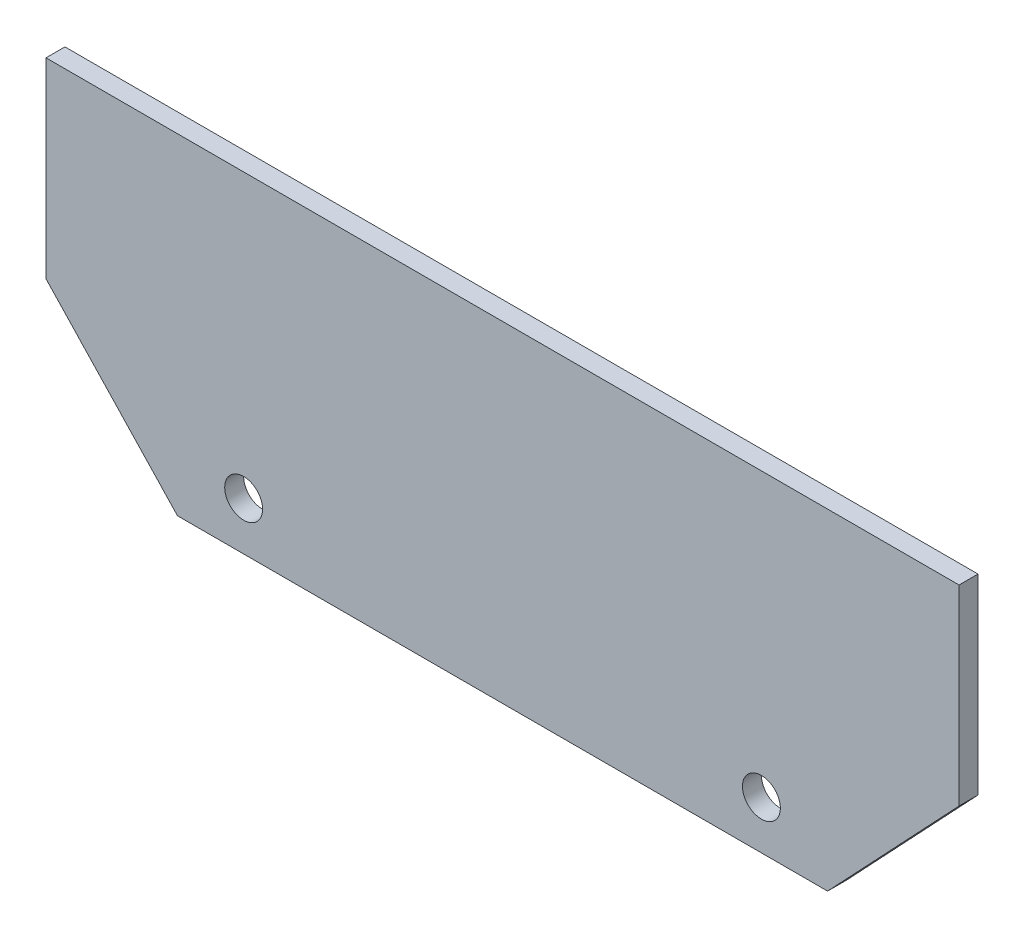
from build123d import *

# Parameters (mm, degrees)
BOSS_EXTRUDE1_DEPTH = 1.5
SKETCH3_R           = 1.5
CUT_EXTRUDE1_DEPTH  = 2.5


with BuildPart() as part:
    # Sketch2 → Boss-Extrude1 (new body)
    with BuildSketch(Plane.XY):
        Polygon((10.41, 0), (61.89, 0), (72.3, 11.044064583), (72.3, 26.2), (0, 26.2), (0, 11.044064583), align=None)
    extrude(amount=BOSS_EXTRUDE1_DEPTH)

    # Sketch3 → Cut-Extrude1 (cut, through all)
    with BuildSketch(Plane(origin=(0, 0, 0), x_dir=(-1, 0, 0), z_dir=(0, 0, -1))):
        with Locations((-56.65, 3.815784405)):
            Circle(SKETCH3_R)
        with Locations((-15.65, 3.815784405)):
            Circle(SKETCH3_R)
    extrude(amount=-CUT_EXTRUDE1_DEPTH, mode=Mode.SUBTRACT)


solid = part.part
